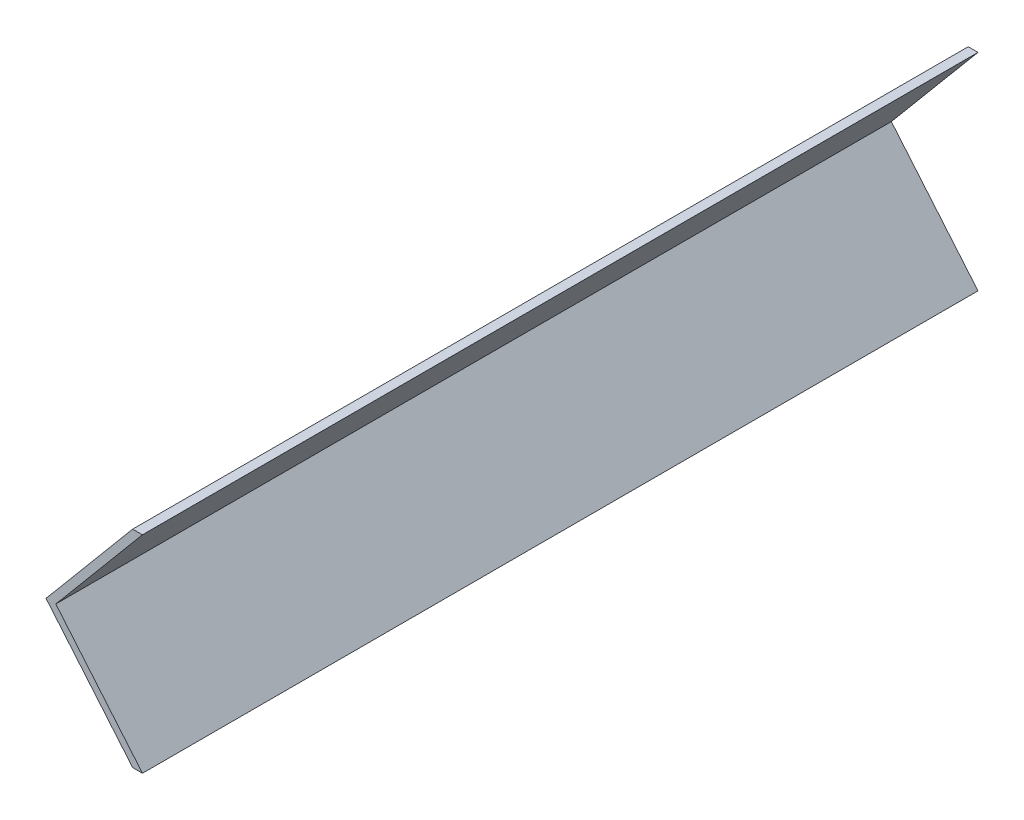
from build123d import *

# Parameters (mm, degrees)
BOSS_EXTRUDE1_DEPTH = 222.5


with BuildPart() as part:
    # Sketch1 → Boss-Extrude1 (new body)
    with BuildSketch(Plane.XY):
        Polygon((0, 0), (-23.075239857, -27.5), (0, -55), (2.610814579, -55), (-20.464425279, -27.5), (2.610814579, 0), align=None)
    extrude(amount=BOSS_EXTRUDE1_DEPTH)


solid = part.part
